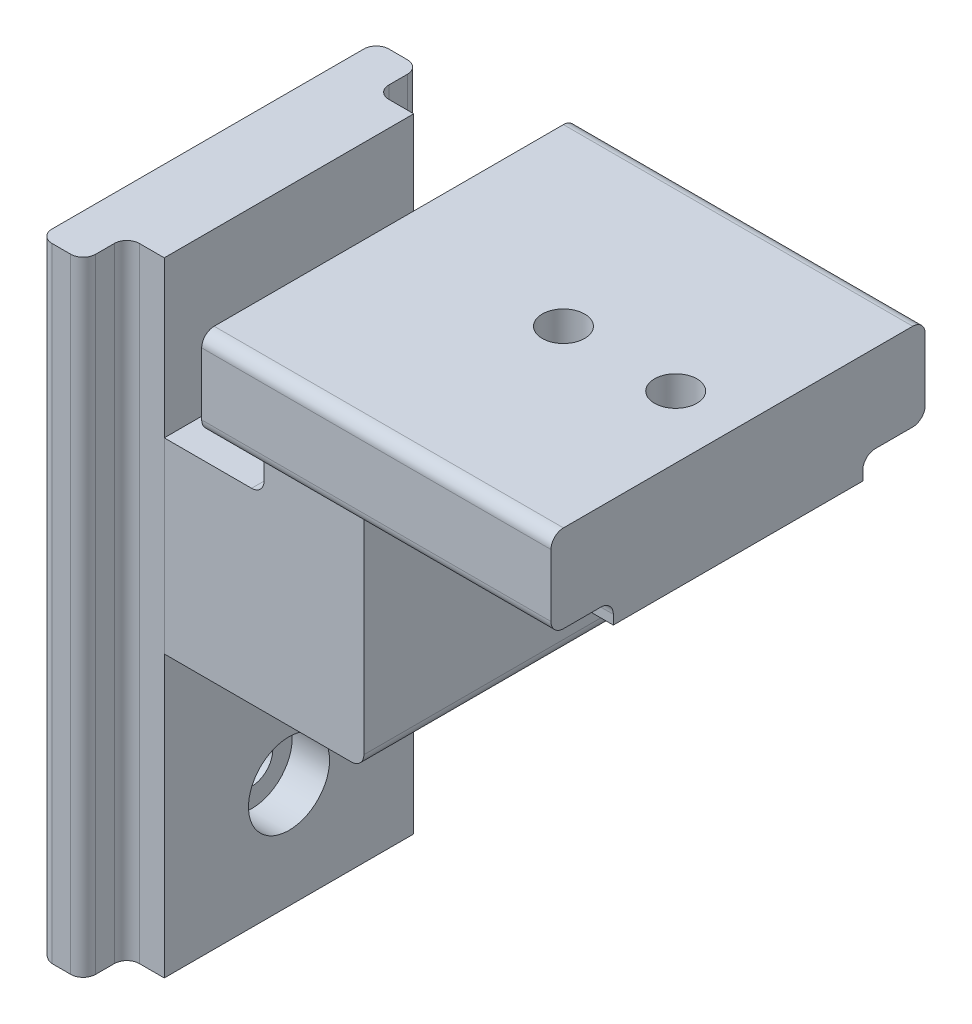
from build123d import *

# Parameters (mm, degrees)
BOSS_EXTRUDE1_DEPTH             = 10
BOSS_EXTRUDE2_DEPTH             = 20
BOSS_EXTRUDE2_DEPTH_BACK        = 30
BOSS_EXTRUDE4_START             = -28
BOSS_EXTRUDE4_DEPTH             = 28
CBORE_FOR_M3_SHCS10_D           = 3.4
CBORE_FOR_M3_SHCS10_CBORE_D     = 6.5
CBORE_FOR_M3_SHCS10_CBORE_DEPTH = 3
CBORE_FOR_M3_SHCS11_D           = 3.4
CBORE_FOR_M3_SHCS11_CBORE_D     = 6.5
CBORE_FOR_M3_SHCS11_CBORE_DEPTH = 3
CBORE_FOR_M3_SHCS13_D           = 3.4
CBORE_FOR_M3_SHCS13_DEPTH       = 18.978536948
CBORE_FOR_M3_SHCS13_CBORE_D     = 6.5
CBORE_FOR_M3_SHCS13_CBORE_DEPTH = 3
CBORE_FOR_M3_SHCS13_TIP         = 1.021463052
FILLET1_R                       = 1


with BuildPart() as part:
    # Sketch1 → Boss-Extrude1 (new body, symmetric)
    with BuildSketch(Plane.XY):
        Polygon((16, -7.5), (0, -7.5), (0, 7.5), (8, 7.5), (8, 12.5), (16, 12.5), align=None)
    extrude(amount=BOSS_EXTRUDE1_DEPTH, both=True)

    # Sketch2 → Boss-Extrude2 (add, two sides)
    with BuildSketch(Plane(origin=(0, 0, 0), x_dir=(1, 0, 0), z_dir=(0, 1, 0))) as boss_extrude2_sk:
        Polygon((-3, 13.5), (-6.5, 13.5), (-6.5, -13.5), (-3, -13.5), (-3, -10), (0, -10), (0, 10), (-3, 10), align=None)
    extrude(amount=BOSS_EXTRUDE2_DEPTH)
    extrude(boss_extrude2_sk.sketch, amount=-BOSS_EXTRUDE2_DEPTH_BACK)

    # Sketch7 → Boss-Extrude4 (add)
    with BuildSketch(Plane.ZY.offset(-8).offset(BOSS_EXTRUDE4_START)):
        Polygon((-10, 12.5), (-10, 14.25), (-15, 14.25), (-15, 21.25), (15, 21.25), (15, 14.25), (10, 14.25), (10, 12.5), align=None)
    extrude(amount=BOSS_EXTRUDE4_DEPTH)

    # CBORE for M3 SHCS10 (through all)
    with Locations(Plane(origin=(0, 12.5, 0), x_dir=(-1, 0, 0), z_dir=(0, -1, 0))):
        with Locations((-22, 0), (-31, 0)):
            CounterBoreHole(CBORE_FOR_M3_SHCS10_D / 2, CBORE_FOR_M3_SHCS10_CBORE_D / 2, CBORE_FOR_M3_SHCS10_CBORE_DEPTH)

    # CBORE for M3 SHCS11 (through all)
    with Locations(Plane(origin=(0, 0, 0), x_dir=(0, 0, -1), z_dir=(1, 0, 0))):
        with Locations((0, -12.5), (0, -21.5)):
            CounterBoreHole(CBORE_FOR_M3_SHCS11_D / 2, CBORE_FOR_M3_SHCS11_CBORE_D / 2, CBORE_FOR_M3_SHCS11_CBORE_DEPTH)

    # CBORE for M3 SHCS13
    with Locations(Plane.ZY.offset(6.5)):
        with Locations((-5, 0), (5, 0)):
            CounterBoreHole(CBORE_FOR_M3_SHCS13_D / 2, CBORE_FOR_M3_SHCS13_CBORE_D / 2, CBORE_FOR_M3_SHCS13_CBORE_DEPTH, depth=CBORE_FOR_M3_SHCS13_DEPTH)
            with Locations((0, 0, -(CBORE_FOR_M3_SHCS13_DEPTH + CBORE_FOR_M3_SHCS13_TIP / 2))):  # 118° drill point
                Cone(0, CBORE_FOR_M3_SHCS13_D / 2, CBORE_FOR_M3_SHCS13_TIP, mode=Mode.SUBTRACT)

    # Fillet1
    fillet1_edges = [part.edges().sort_by_distance(p)[0] for p in [
        (16, -7.5, 0),
        (8, 7.5, 0),
        (-3, -5, -13.5),
        (-3, -5, -10),
        (-3, -5, 10),
        (-3, -5, 13.5),
        (-6.5, -5, 13.5),
        (-6.5, -30, 0),
        (-6.5, -5, -13.5),
        (22, 14.25, -10),
        (22, 14.25, -15),
        (22, 21.25, -15),
        (22, 21.25, 15),
        (22, 14.25, 15),
        (22, 14.25, 10),
    ]]
    fillet(fillet1_edges, radius=FILLET1_R)


with BuildPart() as body_2:
    # Split1: the piece on the far side of the plane
    add(part.part)
    split(bisect_by=Plane(origin=(0, 0, 0), x_dir=(0, 0, 1), z_dir=(1, 0, 0)), keep=Keep.BOTTOM)


with BuildPart() as part_1:
    add(part.part)

    # Split1
    split(bisect_by=Plane(origin=(0, 0, 0), x_dir=(0, 0, 1), z_dir=(1, 0, 0)), keep=Keep.TOP)


solid = Compound([body_2.part, part_1.part])
